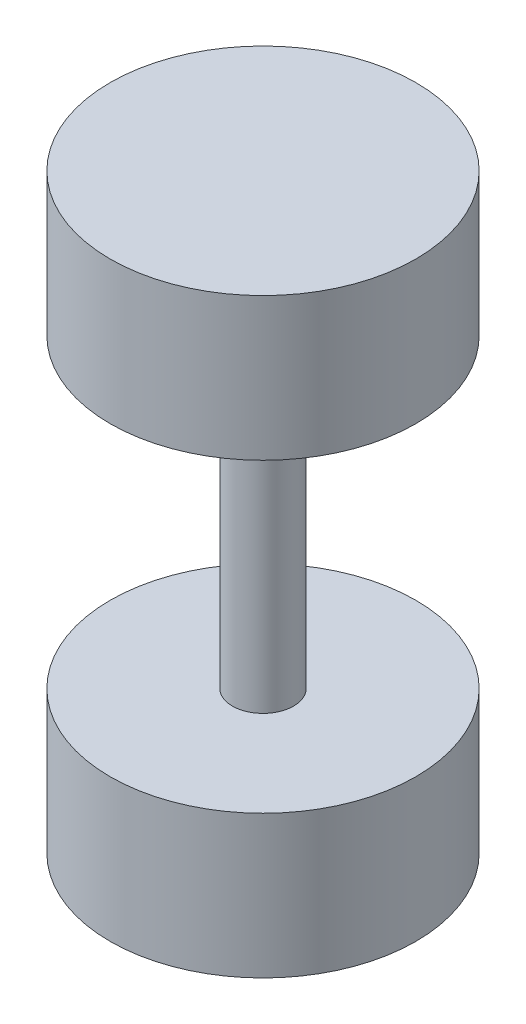
from build123d import *

# Parameters (mm, degrees)
SKETCH1_R           = 7.5
BOSS_EXTRUDE1_DEPTH = 7
SKETCH2_R           = 1.5
BOSS_EXTRUDE2_DEPTH = 15
SKETCH3_W           = 5
SKETCH3_H           = 3.05
CUT_EXTRUDE1_DEPTH  = 6
SKETCH4_R           = 7.5
BOSS_EXTRUDE3_DEPTH = 7


with BuildPart() as part:
    # Sketch1 → Boss-Extrude1 (new body)
    with BuildSketch(Plane(origin=(0, 0, 0), x_dir=(1, 0, 0), z_dir=(0, 1, 0))):
        Circle(SKETCH1_R)
    extrude(amount=BOSS_EXTRUDE1_DEPTH)

    # Sketch2 → Boss-Extrude2 (add)
    with BuildSketch(Plane(origin=(0, 7, 0), x_dir=(1, 0, 0), z_dir=(0, 1, 0))):
        Circle(SKETCH2_R)
    extrude(amount=BOSS_EXTRUDE2_DEPTH)

    # Sketch3 → Cut-Extrude1 (cut)
    with BuildSketch(Plane.XZ):
        Rectangle(SKETCH3_W, SKETCH3_H)
    extrude(amount=-CUT_EXTRUDE1_DEPTH, mode=Mode.SUBTRACT)

    # Sketch4 → Boss-Extrude3 (add)
    with BuildSketch(Plane(origin=(0, 22, 0), x_dir=(1, 0, 0), z_dir=(0, 1, 0))):
        Circle(SKETCH4_R)
    extrude(amount=BOSS_EXTRUDE3_DEPTH)


solid = part.part
